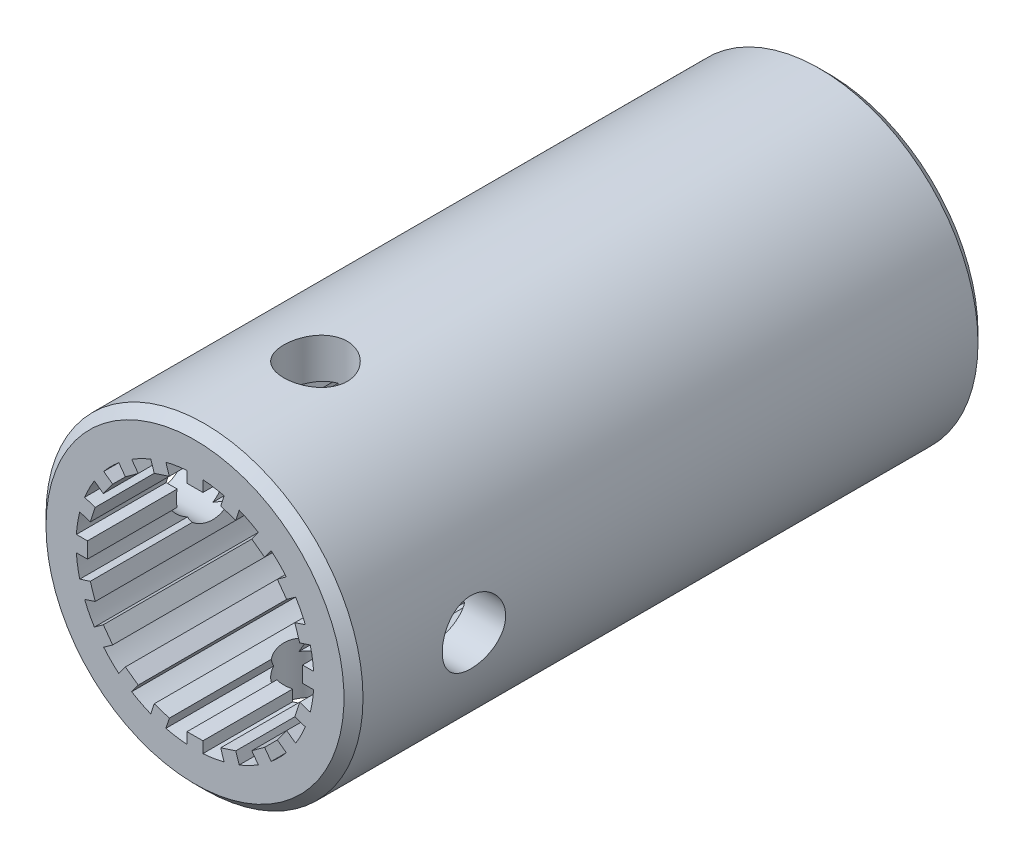
from build123d import *

# Parameters (mm, degrees)
SKETCH1_W          = 50.8
SKETCH1_H          = 12.7
SKETCH2_R          = 2.54
CUT_EXTRUDE1_DEPTH = 17.399
SKETCH3_R          = 2.54
CUT_EXTRUDE2_DEPTH = 17.399
CUT_EXTRUDE3_DEPTH = 21.59
SKETCH5_R          = 9.525
CUT_EXTRUDE4_DEPTH = 26.67
CHAMFER1_SIZE      = 0.762


with BuildPart() as part:
    # Sketch1 → Revolve1 (revolve)
    with BuildSketch(Plane(origin=(0, 0, 0), x_dir=(0, 0, -1), z_dir=(1, 0, 0))):
        with Locations((0, 6.35)):
            Rectangle(SKETCH1_W, SKETCH1_H)
    revolve(axis=Axis((0, 0, 58.877652801), (0, 0, -1)))

    # Sketch2 → Cut-Extrude1 (cut, symmetric)
    with BuildSketch(Plane(origin=(0, 0, 0), x_dir=(1, 0, 0), z_dir=(0, 1, 0))):
        with Locations((0, -15.748)):
            Circle(SKETCH2_R)
    extrude(amount=CUT_EXTRUDE1_DEPTH, both=True, mode=Mode.SUBTRACT)

    # Sketch3 → Cut-Extrude2 (cut, symmetric)
    with BuildSketch(Plane(origin=(0, 0, 0), x_dir=(0, 0, -1), z_dir=(1, 0, 0))):
        with Locations((-15.748, 0)):
            Circle(SKETCH3_R)
    extrude(amount=CUT_EXTRUDE2_DEPTH, both=True, mode=Mode.SUBTRACT)

    # Sketch4 → Cut-Extrude3 (cut)
    with BuildSketch(Plane.XY.offset(25.4)):
        with BuildLine():
            Line((-0.635, 8.614809762), (0.635, 8.614809762))
            Line((0.635, 8.614809762), (0.635, 9.503809762))
            ThreePointArc((0.635, 9.503809762), (1.49003828, 9.407731444), (2.33291784, 9.234885996))
            Line((2.33291784, 9.234885996), (2.058201732, 8.389396753))
            Line((2.058201732, 8.389396753), (3.266043508, 7.99694517))
            Line((3.266043508, 7.99694517), (3.540759616, 8.842434413))
            ThreePointArc((3.540759616, 8.842434413), (4.32425951, 8.486837143), (5.072473428, 8.061987244))
            Line((5.072473428, 8.061987244), (4.549932338, 7.342771136))
            Line((4.549932338, 7.342771136), (5.577383921, 6.596283866))
            Line((5.577383921, 6.596283866), (6.09992501, 7.315499974))
            ThreePointArc((6.09992501, 7.315499974), (6.735192091, 6.735192091), (7.315499974, 6.09992501))
            Line((7.315499974, 6.09992501), (6.596283866, 5.577383921))
            Line((6.596283866, 5.577383921), (7.342771136, 4.549932338))
            Line((7.342771136, 4.549932338), (8.061987244, 5.072473428))
            ThreePointArc((8.061987244, 5.072473428), (8.486837143, 4.32425951), (8.842434413, 3.540759616))
            Line((8.842434413, 3.540759616), (7.99694517, 3.266043508))
            Line((7.99694517, 3.266043508), (8.389396753, 2.058201732))
            Line((8.389396753, 2.058201732), (9.234885996, 2.33291784))
            ThreePointArc((9.234885996, 2.33291784), (9.407731444, 1.49003828), (9.503809762, 0.635))
            Line((9.503809762, 0.635), (8.614809762, 0.635))
            Line((8.614809762, 0.635), (8.614809762, -0.635))
            Line((8.614809762, -0.635), (9.503809762, -0.635))
            ThreePointArc((9.503809762, -0.635), (9.407731444, -1.49003828), (9.234885996, -2.33291784))
            Line((9.234885996, -2.33291784), (8.389396753, -2.058201732))
            Line((8.389396753, -2.058201732), (7.99694517, -3.266043508))
            Line((7.99694517, -3.266043508), (8.842434413, -3.540759616))
            ThreePointArc((8.842434413, -3.540759616), (8.486837143, -4.32425951), (8.061987244, -5.072473428))
            Line((8.061987244, -5.072473428), (7.342771136, -4.549932338))
            Line((7.342771136, -4.549932338), (6.596283866, -5.577383921))
            Line((6.596283866, -5.577383921), (7.315499974, -6.09992501))
            ThreePointArc((7.315499974, -6.09992501), (6.735192091, -6.735192091), (6.09992501, -7.315499974))
            Line((6.09992501, -7.315499974), (5.577383921, -6.596283866))
            Line((5.577383921, -6.596283866), (4.549932338, -7.342771136))
            Line((4.549932338, -7.342771136), (5.072473428, -8.061987244))
            ThreePointArc((5.072473428, -8.061987244), (4.32425951, -8.486837143), (3.540759616, -8.842434413))
            Line((3.540759616, -8.842434413), (3.266043508, -7.99694517))
            Line((3.266043508, -7.99694517), (2.058201732, -8.389396753))
            Line((2.058201732, -8.389396753), (2.33291784, -9.234885996))
            ThreePointArc((2.33291784, -9.234885996), (1.49003828, -9.407731444), (0.635, -9.503809762))
            Line((0.635, -9.503809762), (0.635, -8.614809762))
            Line((0.635, -8.614809762), (-0.635, -8.614809762))
            Line((-0.635, -8.614809762), (-0.635, -9.503809762))
            ThreePointArc((-0.635, -9.503809762), (-1.49003828, -9.407731444), (-2.33291784, -9.234885996))
            Line((-2.33291784, -9.234885996), (-2.058201732, -8.389396753))
            Line((-2.058201732, -8.389396753), (-3.266043508, -7.99694517))
            Line((-3.266043508, -7.99694517), (-3.540759616, -8.842434413))
            ThreePointArc((-3.540759616, -8.842434413), (-4.32425951, -8.486837143), (-5.072473428, -8.061987244))
            Line((-5.072473428, -8.061987244), (-4.549932338, -7.342771136))
            Line((-4.549932338, -7.342771136), (-5.577383921, -6.596283866))
            Line((-5.577383921, -6.596283866), (-6.09992501, -7.315499974))
            ThreePointArc((-6.09992501, -7.315499974), (-6.735192091, -6.735192091), (-7.315499974, -6.09992501))
            Line((-7.315499974, -6.09992501), (-6.596283866, -5.577383921))
            Line((-6.596283866, -5.577383921), (-7.342771136, -4.549932338))
            Line((-7.342771136, -4.549932338), (-8.061987244, -5.072473428))
            ThreePointArc((-8.061987244, -5.072473428), (-8.486837143, -4.32425951), (-8.842434413, -3.540759616))
            Line((-8.842434413, -3.540759616), (-7.99694517, -3.266043508))
            Line((-7.99694517, -3.266043508), (-8.389396753, -2.058201732))
            Line((-8.389396753, -2.058201732), (-9.234885996, -2.33291784))
            ThreePointArc((-9.234885996, -2.33291784), (-9.407731444, -1.49003828), (-9.503809762, -0.635))
            Line((-9.503809762, -0.635), (-8.614809762, -0.635))
            Line((-8.614809762, -0.635), (-8.614809762, 0.635))
            Line((-8.614809762, 0.635), (-9.503809762, 0.635))
            ThreePointArc((-9.503809762, 0.635), (-9.407731444, 1.49003828), (-9.234885996, 2.33291784))
            Line((-9.234885996, 2.33291784), (-8.389396753, 2.058201732))
            Line((-8.389396753, 2.058201732), (-7.99694517, 3.266043508))
            Line((-7.99694517, 3.266043508), (-8.842434413, 3.540759616))
            ThreePointArc((-8.842434413, 3.540759616), (-8.486837143, 4.32425951), (-8.061987244, 5.072473428))
            Line((-8.061987244, 5.072473428), (-7.342771136, 4.549932338))
            Line((-7.342771136, 4.549932338), (-6.596283866, 5.577383921))
            Line((-6.596283866, 5.577383921), (-7.315499974, 6.09992501))
            ThreePointArc((-7.315499974, 6.09992501), (-6.735192091, 6.735192091), (-6.09992501, 7.315499974))
            Line((-6.09992501, 7.315499974), (-5.577383921, 6.596283866))
            Line((-5.577383921, 6.596283866), (-4.549932338, 7.342771136))
            Line((-4.549932338, 7.342771136), (-5.072473428, 8.061987244))
            ThreePointArc((-5.072473428, 8.061987244), (-4.32425951, 8.486837143), (-3.540759616, 8.842434413))
            Line((-3.540759616, 8.842434413), (-3.266043508, 7.99694517))
            Line((-3.266043508, 7.99694517), (-2.058201732, 8.389396753))
            Line((-2.058201732, 8.389396753), (-2.33291784, 9.234885996))
            ThreePointArc((-2.33291784, 9.234885996), (-1.49003828, 9.407731444), (-0.635, 9.503809762))
            Line((-0.635, 9.503809762), (-0.635, 8.614809762))
        make_face()
    extrude(amount=-CUT_EXTRUDE3_DEPTH, mode=Mode.SUBTRACT)

    # Sketch5 → Cut-Extrude4 (cut)
    with BuildSketch(Plane(origin=(0, 0, -25.4), x_dir=(-1, 0, 0), z_dir=(0, 0, -1))):
        Circle(SKETCH5_R)
    extrude(amount=-CUT_EXTRUDE4_DEPTH, mode=Mode.SUBTRACT)

    # Chamfer1
    chamfer1_edges = [part.edges().sort_by_distance(p)[0] for p in [
        (9.525, 0, -25.4),
        (0, -12.7, -25.4),
        (0, -12.7, 25.4),
    ]]
    chamfer(chamfer1_edges, length=CHAMFER1_SIZE)


solid = part.part
